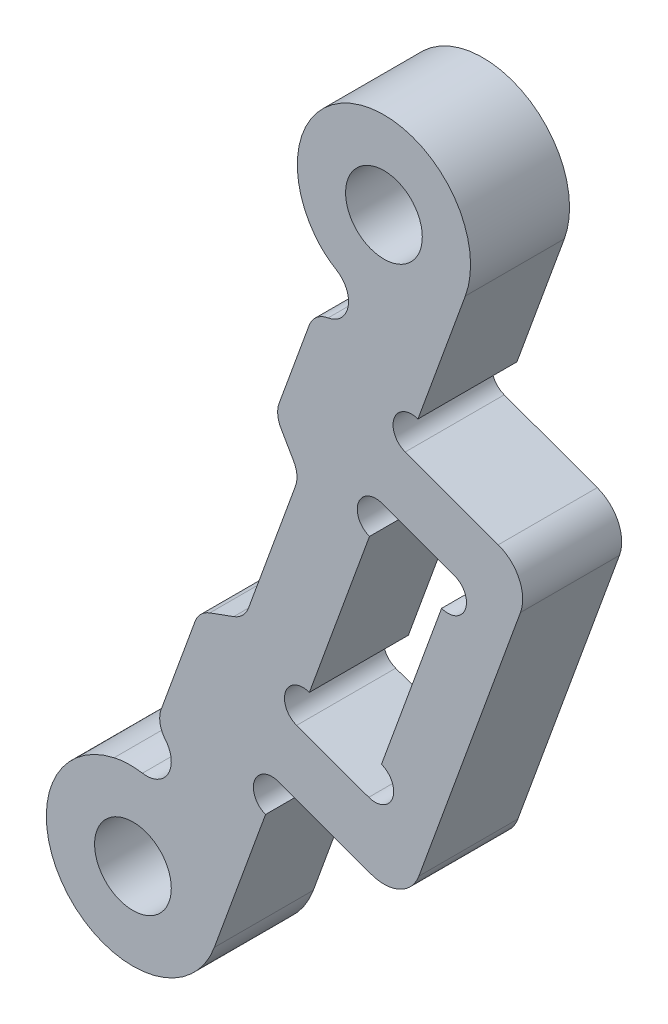
from build123d import *

# Parameters (mm, degrees)
SKETCH_1_R             = 7
SKETCH_1_R_2           = 1.55
EXTRUDE_1_DEPTH        = 2
FILLET_1_R             = 1
CUT_EXTRUDE_START      = -5
CUT_EXTRUDE_1_DEPTH    = 6
FILLET_2_R             = 1
FILLET_2_OF_MIRROR_1_R = 1
SKETCH_3_R             = 1.55
EXTRUDE_2_DEPTH        = 4
FILLET_3_R             = 1
CUT_EXTRUDE_2_DEPTH    = 5
FILLET_4_R             = 1
CUT_EXTRUDE_3_DEPTH    = 5
EXTRUDE_3_DEPTH        = 4
SKETCH_8_R             = 0.75
CUT_EXTRUDE_4_DEPTH    = 5
FILLET_5_R             = 1.5
CUT_EXTRUDE_5_DEPTH    = 5
EXTRUDE_4_DEPTH        = 4
CUT_EXTRUDE_6_DEPTH    = 5
SKETCH_12_R            = 1
CUT_EXTRUDE_7_DEPTH    = 5
FILLET_6_R             = 3
FILLET_7_R             = 1
FILLET_8_R             = 1


with BuildPart() as part:
    # 草图1 → 凸台-拉伸1 (new body, symmetric)
    with BuildSketch(Plane.XY):
        with BuildLine():
            Line((-17.5, 11), (-10, 11))
            Line((-10, 11), (-8.321800738, 9))
            Line((-8.321800738, 9), (8.321800738, 9))
            Line((8.321800738, 9), (10, 11))
            Line((10, 11), (17.5, 11))
            ThreePointArc((17.5, 11), (17.577641076, 10.999138732), (17.655243941, 10.99655535))
            Line((17.655243941, 10.99655535), (37, 10.137665421))
            Line((37, 10.137665421), (28.942548731, -12))
            Line((28.942548731, -12), (17.199216279, -10.987051642))
            ThreePointArc((17.199216279, -10.987051642), (15.184578245, -10.124656567), (14.077678472, -8.233290774))
            Line((14.077678472, -8.233290774), (2.304628146, -10.75586766))
            ThreePointArc((2.304628146, -10.75586766), (0, -11), (-2.304628146, -10.75586766))
            Line((-2.304628146, -10.75586766), (-14.077678472, -8.233290774))
            ThreePointArc((-14.077678472, -8.233290774), (-15.184578245, -10.124656567), (-17.199216279, -10.987051642))
            Line((-17.199216279, -10.987051642), (-28.942548731, -12))
            Line((-28.942548731, -12), (-37, 10.137665421))
            Line((-37, 10.137665421), (-17.655243941, 10.99655535))
            ThreePointArc((-17.655243941, 10.99655535), (-17.577641076, 10.999138732), (-17.5, 11))
        make_face()
        Circle(SKETCH_1_R, mode=Mode.SUBTRACT)
        with Locations((17.5, 7.5)):
            Circle(SKETCH_1_R_2, mode=Mode.SUBTRACT)
        with Locations((17.5, -7.5)):
            Circle(SKETCH_1_R_2, mode=Mode.SUBTRACT)
        with Locations((-17.5, -7.5)):
            Circle(SKETCH_1_R_2, mode=Mode.SUBTRACT)
        with Locations((-17.5, 7.5)):
            Circle(SKETCH_1_R_2, mode=Mode.SUBTRACT)
    extrude(amount=EXTRUDE_1_DEPTH, both=True)

    # 圆角1
    fillet_1_edges = [part.edges().sort_by_distance(p)[0] for p in [
        (14.077678472, -8.233290774, 0),
        (-14.077678472, -8.233290774, 0),
    ]]
    fillet(fillet_1_edges, radius=FILLET_1_R)

    # 草图2 → 切除-拉伸1 (cut)
    with BuildSketch(Plane.XY.offset(2).offset(CUT_EXTRUDE_START)):
        Polygon((-20.5, 7.867295251), (-32.782632739, 7.321957304), (-27.222903771, -7.953272497), align=None)
        with BuildLine():
            Line((-19.251811465, 4.412338006), (-24.573190843, -8.11011447))
            Line((-24.573190843, -8.11011447), (-21.036866665, -7.805080632))
            ThreePointArc((-21.036866665, -7.805080632), (-20.623106229, -5.812188553), (-19.182687898, -4.374130291))
            Line((-19.182687898, -4.374130291), (-15.331076504, 4.689613751))
            ThreePointArc((-15.331076504, 4.689613751), (-17.24956823, 3.958844267), (-19.251811465, 4.412338006))
        make_face()
    cut_extrude_1 = extrude(amount=CUT_EXTRUDE_1_DEPTH, mode=Mode.SUBTRACT)

    # 圆角2
    fillet_2_edges = [part.edges().sort_by_distance(p)[0] for p in [
        (-20.5, 7.867295251, 0),
        (-27.222903771, -7.953272497, 0),
        (-32.782632739, 7.321957304, 0),
        (-19.251811465, 4.412338006, 0),
        (-15.331076504, 4.689613751, 0),
        (-19.182687898, -4.374130291, 0),
        (-21.036866665, -7.805080632, 0),
        (-24.573190843, -8.11011447, 0),
    ]]
    fillet(fillet_2_edges, radius=FILLET_2_R)

    # 镜向1: 切除-拉伸1 across plane
    add(cut_extrude_1.mirror(Plane(origin=(0, 0, 0), x_dir=(0, 0, 1), z_dir=(1, 0, 0))), mode=Mode.SUBTRACT)

    # 圆角2 of 镜向1
    fillet_2_of_mirror_1_edges = [part.edges().sort_by_distance(p)[0] for p in [
        (20.5, 7.867295251, 0),
        (27.222903771, -7.953272497, 0),
        (32.782632739, 7.321957304, 0),
        (19.251811465, 4.412338006, 0),
        (15.331076504, 4.689613751, 0),
        (19.182687898, -4.374130291, 0),
        (21.036866665, -7.805080632, 0),
        (24.573190843, -8.11011447, 0),
    ]]
    fillet(fillet_2_of_mirror_1_edges, radius=FILLET_2_OF_MIRROR_1_R)

    # 草图3 → 凸台-拉伸2 (add)
    with BuildSketch(Plane.XY.offset(2)):
        with BuildLine():
            Line((-37.69913918, 12.058534531), (-37, 10.137665421))
            Line((-37, 10.137665421), (-32.4761474, 10.338520445))
            ThreePointArc((-32.4761474, 10.338520445), (-33.315445081, 16.579981486), (-37.69913918, 12.058534531))
        make_face()
        with Locations((-34.410215007, 13.255605032)):
            Circle(SKETCH_3_R, mode=Mode.SUBTRACT)
        with BuildLine():
            Line((-27.557621455, -15.805056417), (-28.942548731, -12))
            Line((-28.942548731, -12), (-22.730405687, -11.464157204))
            ThreePointArc((-22.730405687, -11.464157204), (-21.928391725, -17.210478932), (-27.557621455, -15.805056417))
        make_face()
        with Locations((-24.268697282, -14.607985915)):
            Circle(SKETCH_3_R, mode=Mode.SUBTRACT)
    extrude_2 = extrude(amount=-EXTRUDE_2_DEPTH)

    # 镜向2: 凸台-拉伸2 across plane
    add(extrude_2.mirror(Plane(origin=(0, 0, 0), x_dir=(0, 0, 1), z_dir=(1, 0, 0))))

    # 圆角3
    fillet_3_edges = [part.edges().sort_by_distance(p)[0] for p in [
        (-22.730405687, -11.464157204, 0),
        (-32.4761474, 10.338520445, 0),
        (22.730405687, -11.464157204, 0),
        (32.4761474, 10.338520445, 0),
    ]]
    fillet(fillet_3_edges, radius=FILLET_3_R)

    # 草图4 → 切除-拉伸2 (cut, through all)
    with BuildSketch(Plane.XY.offset(2)):
        with BuildLine():
            Line((-16.384851826, -4.1824038), (-12.057869255, 6))
            Line((-12.057869255, 6), (-8, 6))
            ThreePointArc((-8, 6), (-9.993390733, -0.363512948), (-7.542930102, -6.565379309))
            Line((-7.542930102, -6.565379309), (-15.108699944, -4.944284045))
            ThreePointArc((-15.108699944, -4.944284045), (-15.705867849, -4.49482283), (-16.384851826, -4.1824038))
        make_face()
    cut_extrude_2 = extrude(amount=-CUT_EXTRUDE_2_DEPTH, mode=Mode.SUBTRACT)

    # 镜向3: 切除-拉伸2 across plane
    add(cut_extrude_2.mirror(Plane(origin=(0, 0, 0), x_dir=(0, 0, 1), z_dir=(1, 0, 0))), mode=Mode.SUBTRACT)

    # 圆角4
    fillet_4_edges = [part.edges().sort_by_distance(p)[0] for p in [
        (-12.057869255, 6, 0),
        (-8, 6, 0),
        (-7.542930102, -6.565379309, 0),
        (-15.108699944, -4.944284045, 0),
        (-16.384851826, -4.1824038, 0),
        (8, 6, 0),
        (12.057869255, 6, 0),
        (16.384851826, -4.1824038, 0),
        (15.108699944, -4.944284045, 0),
        (7.542930102, -6.565379309, 0),
    ]]
    fillet(fillet_4_edges, radius=FILLET_4_R)

    # 草图5 → 切除-拉伸3 (cut, through all)
    with BuildSketch(Plane.XY.offset(2)):
        Polygon((30.884976598, -6.370842854), (33.798023723, -7.431105298), (37.25242717, 2.059790172), (34.339380046, 3.120052616), align=None)
    cut_extrude_3 = extrude(amount=-CUT_EXTRUDE_3_DEPTH, mode=Mode.SUBTRACT)

    # 草图7 → 凸台-拉伸3 (add)
    with BuildSketch(Plane.XY.offset(2)):
        Polygon((35.271298659, 5.388097522), (40.439608074, 3.506986734), (35.309305924, -10.588402578), (30.140996509, -8.707291789), (30.97894586, -6.405044868), (33.798023723, -7.431105298), (37.25242717, 2.059790172), (34.433349308, 3.085850601), align=None)
    extrude_3 = extrude(amount=-EXTRUDE_3_DEPTH)

    # 镜向4: 切除-拉伸3, 凸台-拉伸3 across plane
    add(cut_extrude_3.mirror(Plane(origin=(0, 0, 0), x_dir=(0, 0, 1), z_dir=(1, 0, 0))), mode=Mode.SUBTRACT)
    add(extrude_3.mirror(Plane(origin=(0, 0, 0), x_dir=(0, 0, 1), z_dir=(1, 0, 0))))

    # 草图8 → 切除-拉伸4 (cut, through all)
    with BuildSketch(Plane(origin=(0, 0, -2), x_dir=(-1, 0, 0), z_dir=(0, 0, -1))):
        with Locations((-36.995912063, 1.355020706)):
            Circle(SKETCH_8_R)
        with Locations((-34.082864939, 2.41528315)):
            Circle(SKETCH_8_R)
        with Locations((-34.05453883, -6.726335833)):
            Circle(SKETCH_8_R)
        with Locations((-31.141491706, -5.666073389)):
            Circle(SKETCH_8_R)
        with Locations((-35.527813767, 6.092866988)):
            Circle(SKETCH_8_R)
        with Locations((-29.884481402, -9.412061255)):
            Circle(SKETCH_8_R)
    cut_extrude_4 = extrude(amount=-CUT_EXTRUDE_4_DEPTH, mode=Mode.SUBTRACT)

    # 镜向5: 切除-拉伸4 across plane
    add(cut_extrude_4.mirror(Plane(origin=(0, 0, 0), x_dir=(0, 0, 1), z_dir=(1, 0, 0))), mode=Mode.SUBTRACT)

    # 圆角5
    fillet_5_edges = [part.edges().sort_by_distance(p)[0] for p in [
        (40.439608074, 3.506986734, 0),
        (35.309305924, -10.588402578, 0),
        (-40.439608074, 3.506986734, 0),
        (-35.309305924, -10.588402578, 0),
    ]]
    fillet(fillet_5_edges, radius=FILLET_5_R)

    # 草图9 → 切除-拉伸5 (cut, through all)
    with BuildSketch(Plane(origin=(0, 0, -2), x_dir=(-1, 0, 0), z_dir=(0, 0, -1))):
        with BuildLine():
            Line((-32.316536273, 6.041367788), (-33.695268787, 9.829404235))
            ThreePointArc((-33.695268787, 9.829404235), (-30.928713694, 13.614977548), (-34.410215007, 16.755605032))
            Line((-34.410215007, 16.755605032), (45.589784993, 16.755605032))
            Line((45.589784993, 16.755605032), (45.589784993, -18.107985915))
            Line((45.589784993, -18.107985915), (-24.268697282, -18.107985915))
            ThreePointArc((-24.268697282, -18.107985915), (-20.874243549, -13.754942039), (-25.923336124, -11.523805262))
            Line((-25.923336124, -11.523805262), (-28.090663396, -5.56912252))
            Line((-28.090663396, -5.56912252), (-32.316536273, 6.041367788))
        make_face()
    extrude(amount=-CUT_EXTRUDE_5_DEPTH, mode=Mode.SUBTRACT)

    # 草图10 → 凸台-拉伸4 (add)
    with BuildSketch(Plane(origin=(0, 0, -2), x_dir=(-1, 0, 0), z_dir=(0, 0, -1))):
        with BuildLine():
            Line((-32.323351951, 10.445800309), (-24.476175097, -11.114140905))
            ThreePointArc((-24.476175097, -11.114140905), (-25.222020853, -11.240319933), (-25.923336124, -11.523805262))
            Line((-25.923336124, -11.523805262), (-33.695268787, 9.829404235))
            ThreePointArc((-33.695268787, 9.829404235), (-32.975809264, 10.063038641), (-32.323351951, 10.445800309))
        make_face()
    extrude(amount=-EXTRUDE_4_DEPTH)

    # 草图11 → 切除-拉伸6 (cut, through all)
    with BuildSketch(Plane(origin=(0, 0, -2), x_dir=(-1, 0, 0), z_dir=(0, 0, -1))):
        Polygon((-30.016621436, 4.108110305), (-30.995676903, 2.412336493), (-28.778462541, -3.6794099), (-26.938440146, -4.349123282), align=None)
    extrude(amount=-CUT_EXTRUDE_6_DEPTH, mode=Mode.SUBTRACT)

    # 草图12 → 切除-拉伸7 (cut, through all)
    with BuildSketch(Plane(origin=(0, 0, -2), x_dir=(-1, 0, 0), z_dir=(0, 0, -1))):
        with Locations((-31.981331808, 9.506107688)):
            Circle(SKETCH_12_R)
        with Locations((-24.81819524, -10.174448284)):
            Circle(SKETCH_12_R)
    extrude(amount=-CUT_EXTRUDE_7_DEPTH, mode=Mode.SUBTRACT)

    # 圆角6
    fillet_6_edges = [part.edges().sort_by_distance(p)[0] for p in [
        (24.476175097, -11.114140905, 0),
        (32.323351951, 10.445800309, 0),
    ]]
    fillet(fillet_6_edges, radius=FILLET_6_R)

    # 圆角7
    fillet_7_edges = [part.edges().sort_by_distance(p)[0] for p in [
        (28.778462541, -3.6794099, 0),
        (30.995676903, 2.412336493, 0),
    ]]
    fillet(fillet_7_edges, radius=FILLET_7_R)

    # 圆角8
    fillet_8_edges = [part.edges().sort_by_distance(p)[0] for p in [
        (30.016621436, 4.108110305, 0),
        (26.938440146, -4.349123282, 0),
        (31.639311664, 8.566415067, 0),
        (25.160215383, -9.234755664, 0),
    ]]
    fillet(fillet_8_edges, radius=FILLET_8_R)


solid = part.part
